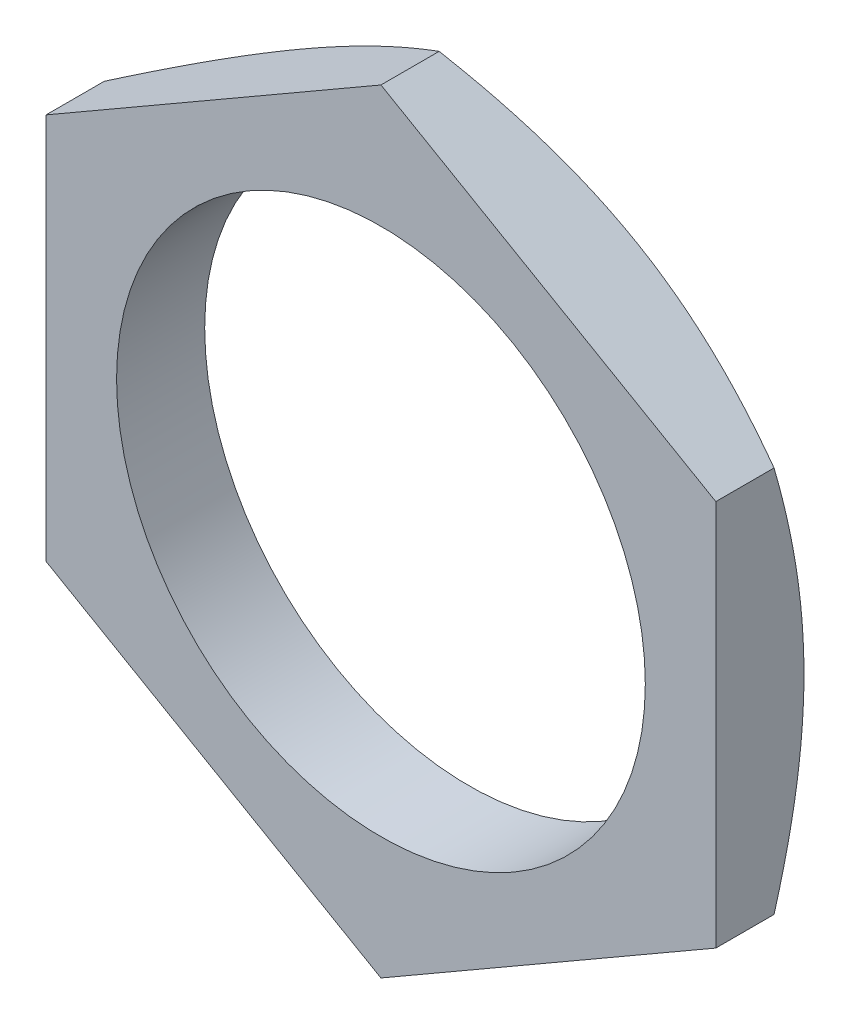
from build123d import *

# Parameters (mm, degrees)
SKETCH1_R           = 7.5
BOSS_EXTRUDE1_DEPTH = 1.25


with BuildPart() as part:
    # Sketch1 → Boss-Extrude1 (new body, symmetric)
    with BuildSketch(Plane.XY):
        Polygon((0, 10.969655115), (-9.5, 5.484827557), (-9.5, -5.484827557), (0, -10.969655115), (9.5, -5.484827557), (9.5, 5.484827557), align=None)
        Circle(SKETCH1_R, mode=Mode.SUBTRACT)
    extrude(amount=BOSS_EXTRUDE1_DEPTH, both=True)

    # Sketch2 → Cut-Revolve1 (revolve, cut)
    with BuildSketch(Plane(origin=(0, 0, 0), x_dir=(1, 0, 0), z_dir=(0, 1, 0))):
        Polygon((-9.5, 1.25), (-12.977549271, -0.757764008), (-12.977549271, 1.25), align=None)
    revolve(axis=Axis((0, 0, 0), (0, 0, -1)), mode=Mode.SUBTRACT)


solid = part.part
